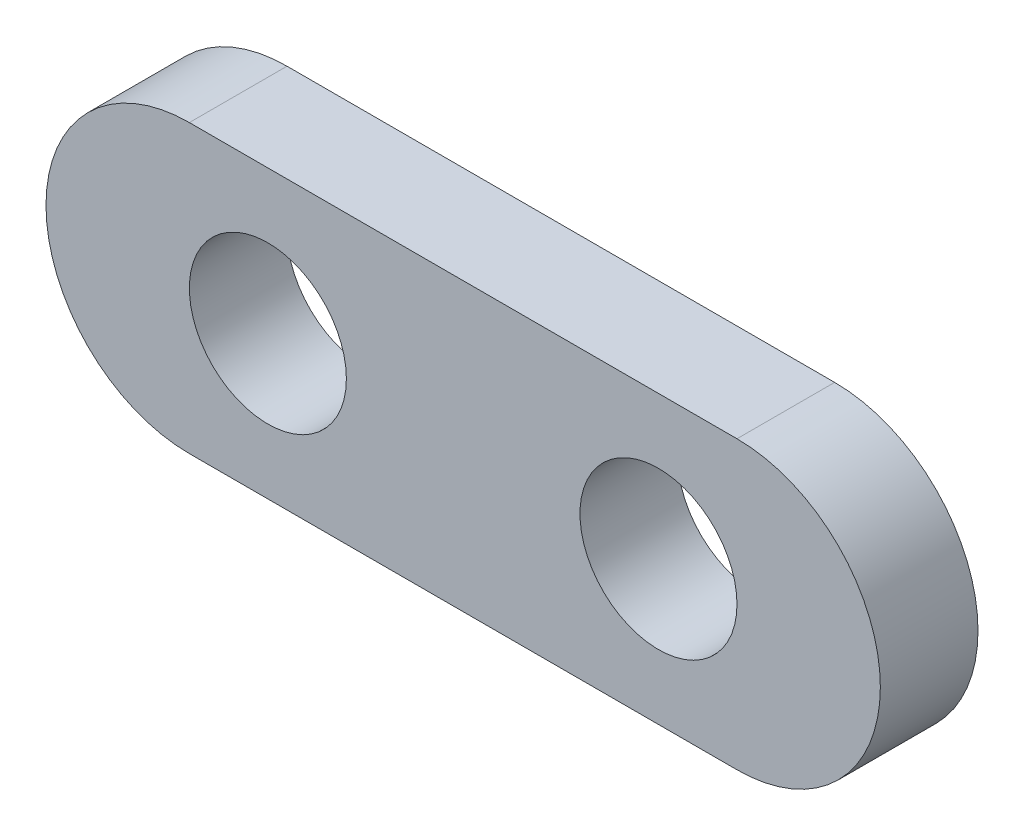
from build123d import *

# Parameters (mm, degrees)
SKETCH_1_R      = 2.5527
EXTRUDE_1_DEPTH = 3.175


with BuildPart() as part:
    # Эскиз1 → Бобышка-Вытянуть1 (new body)
    with BuildSketch(Plane.XY):
        with BuildLine():
            Line((8.9027, 4.6609), (-8.9027, 4.6609))
            ThreePointArc((-8.9027, 4.6609), (-13.5636, 0), (-8.9027, -4.6609))
            Line((-8.9027, -4.6609), (8.9027, -4.6609))
            ThreePointArc((8.9027, -4.6609), (13.5636, 0), (8.9027, 4.6609))
        make_face()
        with Locations((-6.35, 0)):
            Circle(SKETCH_1_R, mode=Mode.SUBTRACT)
        with Locations((6.35, 0)):
            Circle(SKETCH_1_R, mode=Mode.SUBTRACT)
    extrude(amount=EXTRUDE_1_DEPTH)


solid = part.part
